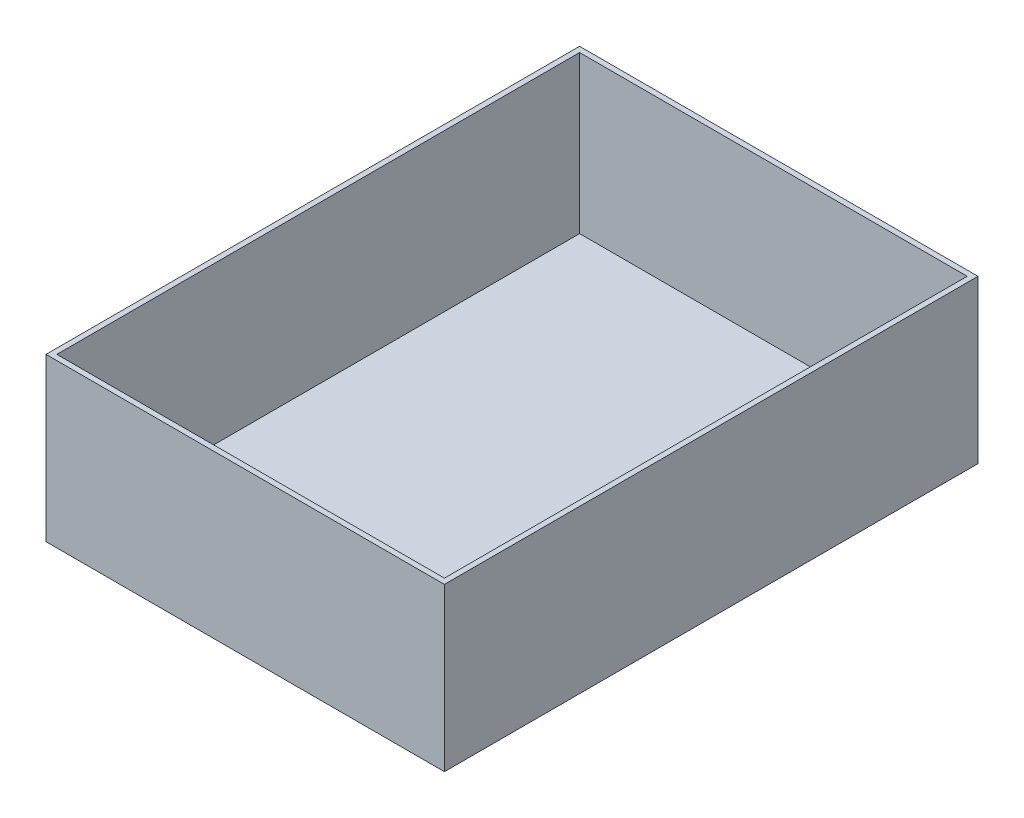
from build123d import *

# Parameters (mm, degrees)
SKIZZE1_W                       = 215
SKIZZE1_H                       = 87
AUFSATZ_LINEAR_AUSTRAGEN1_DEPTH = 145
WANDUNG1_T                      = 3


with BuildPart() as part:
    # Skizze1 → Aufsatz-Linear austragen1 (new, symmetric)
    with BuildSketch(Plane.XY):
        Rectangle(SKIZZE1_W, SKIZZE1_H)
    extrude(amount=AUFSATZ_LINEAR_AUSTRAGEN1_DEPTH, both=True)

    # Wandung1
    wandung1_openings = [part.faces().sort_by_distance(p)[0] for p in [
        (0, 43.5, 0),
    ]]
    offset(amount=WANDUNG1_T, openings=wandung1_openings, kind=Kind.INTERSECTION)


solid = part.part
